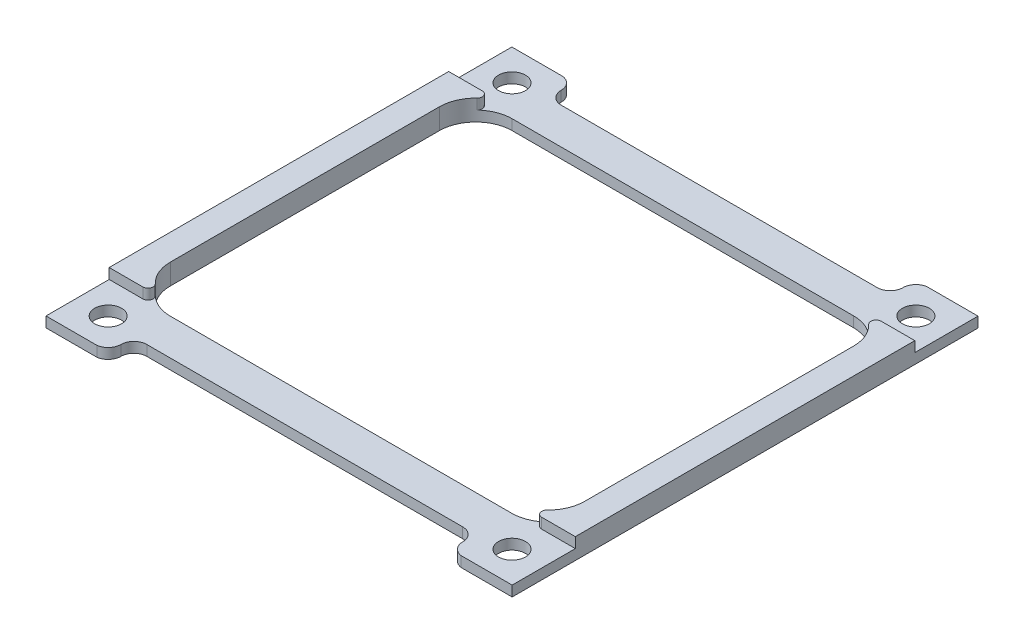
from build123d import *

# Parameters (mm, degrees)
SKETCH_1_W          = 90.03018306390481
SKETCH_1_H          = 89.97022234109225
SKETCH_1_R          = 2.599999999999996
SKETCH_1_W_2        = 65.97077516555349
SKETCH_1_H_2        = 66.02977765890743
EXTRUDE_1_DEPTH     = 2
CUT_EXTRUDE_1_DEPTH = 64.67117630966501
CUT_EXTRUDE_2_DEPTH = 64.67117630966501
EXTRUDE_START       = 2
EXTRUDE_2_DEPTH     = 2
FILLET_1_R          = 1


with BuildPart() as part:
    # 草图1 → 凸台-拉伸1 (new body)
    with BuildSketch(Plane(origin=(0, 0, 0), x_dir=(1, 0, 0), z_dir=(0, 1, 0))):
        Rectangle(SKETCH_1_W, SKETCH_1_H)
        with Locations(Location((39.00000000000001, 38.99999999999999, 0), (0, 0, 270))):
            Circle(SKETCH_1_R, mode=Mode.SUBTRACT)
        with Locations(Location((39.000000000000014, -39.00000000000001, 0), (0, 0, 270))):
            Circle(SKETCH_1_R, mode=Mode.SUBTRACT)
        with Locations(Location((-38.99999999999998, -39.00000000000001, 0), (0, 0, 270))):
            Circle(SKETCH_1_R, mode=Mode.SUBTRACT)
        with Locations(Location((-38.99999999999999, 38.99999999999999, 0), (0, 0, 270))):
            Circle(SKETCH_1_R, mode=Mode.SUBTRACT)
        Rectangle(SKETCH_1_W_2, SKETCH_1_H_2, mode=Mode.SUBTRACT)
    extrude(amount=EXTRUDE_1_DEPTH)

    # 草图3 → 切除-拉伸1 (cut, through all)
    with BuildSketch(Plane(origin=(0, 2, 0), x_dir=(1, 0, 0), z_dir=(0, 1, 0))):
        with BuildLine():
            Line((35.16632906527342, 44.985111170546105), (-35.16632906527342, 44.985111170546126))
            ThreePointArc((-35.16632906527342, 44.98511117054611), (-33.623759393307296, 44.150934913211564), (-33.00868514907322, 42.50866365204603))
            ThreePointArc((-33.00868514907322, 42.50866365204603), (-32.2698933068484, 40.74672362699537), (-30.502504505895168, 40.02106333162392))
            Line((-30.502504505895168, 40.02106333162392), (30.502504505895196, 40.0210633316239))
            ThreePointArc((30.502504505895196, 40.0210633316239), (32.269893306848424, 40.74672362699535), (33.00868514907325, 42.50866365204601))
            ThreePointArc((33.00868514907325, 42.50866365204601), (33.62375939330732, 44.150934913211536), (35.16632906527342, 44.98511117054609))
        make_face()
        with BuildLine():
            Line((30.502504505895207, -40.0210633316239), (-30.502504505895114, -40.02106333162392))
            ThreePointArc((-30.502504505895114, -40.02106333162392), (-32.269893306848346, -40.74672362699537), (-33.008685149073166, -42.50866365204603))
            ThreePointArc((-33.008685149073166, -42.50866365204603), (-33.62375939330724, -44.150934913211564), (-35.166329065273366, -44.98511117054611))
            Line((-35.166329065273366, -44.985111170546126), (35.16632906527344, -44.985111170546105))
            ThreePointArc((35.16632906527343, -44.98511117054609), (33.623759393307324, -44.150934913211536), (33.00868514907326, -42.50866365204601))
            ThreePointArc((33.00868514907326, -42.50866365204601), (32.26989330684843, -40.74672362699535), (30.502504505895203, -40.0210633316239))
        make_face()
    extrude(amount=-CUT_EXTRUDE_1_DEPTH, mode=Mode.SUBTRACT)

    # 草图4 → 切除-拉伸2 (cut, through all)
    with BuildSketch(Plane(origin=(0, 2, 0), x_dir=(1, 0, 0), z_dir=(0, 1, 0))):
        with BuildLine():
            Line((-32.985387582776745, -33.01488882945372), (-32.985387582776724, 33.01488882945372))
            ThreePointArc((-32.985387582776724, 33.01488882945372), (-37.9510386162303, 30.950835913733954), (-40.0150915319524, 25.985184880281345))
            Line((-40.01509153195237, 25.985184880281345), (-40.01509153195237, 25.95025335742635))
            Line((-40.01509153195237, 25.95025335742635), (-40.0150915319524, -25.95025335742637))
            Line((-40.0150915319524, -25.95025335742637), (-40.0150915319524, -25.985184880281345))
            ThreePointArc((-40.015091531952386, -25.985184880281345), (-37.95103861623032, -30.950835913733957), (-32.985387582776745, -33.01488882945372))
        make_face()
        with BuildLine():
            Line((40.01509153195237, 25.950253357426362), (40.01509153195237, 25.985184880281345))
            ThreePointArc((40.0150915319524, 25.985184880281345), (37.9510386162303, 30.95083591373395), (32.985387582776724, 33.01488882945372))
            Line((32.985387582776724, 33.01488882945372), (32.985387582776745, -33.01488882945372))
            ThreePointArc((32.985387582776745, -33.01488882945372), (37.95103861623032, -30.950835913733957), (40.0150915319524, -25.985184880281345))
            Line((40.0150915319524, -25.985184880281345), (40.0150915319524, -25.950253357426362))
            Line((40.0150915319524, -25.950253357426362), (40.01509153195237, 25.950253357426362))
        make_face()
    extrude(amount=-CUT_EXTRUDE_2_DEPTH, mode=Mode.SUBTRACT)

    # 草图5 → 凸台-拉伸2 (add)
    with BuildSketch(Plane(origin=(0, 2, 0), x_dir=(1, 0, 0), z_dir=(0, 1, 0)).offset(EXTRUDE_START)):
        with BuildLine():
            Line((45.015091531952415, -32.78514802541212), (45.015091531952415, 32.78514802541212))
            Line((45.015091531952415, 32.78514802541212), (34.75273808271875, 32.78514802541212))
            ThreePointArc((34.75273808271875, 32.78514802541213), (38.54114967835172, 30.28072702943986), (40.01509153195237, 25.985184880281345))
            Line((40.01509153195237, 25.985184880281345), (40.0150915319524, -25.985184880281345))
            ThreePointArc((40.0150915319524, -25.985184880281345), (38.54114967835175, -30.280727029439863), (34.75273808271877, -32.78514802541212))
            Line((34.75273808271877, -32.78514802541212), (45.015091531952415, -32.78514802541212))
        make_face()
        with BuildLine():
            Line((-45.01509153195241, 32.78514802541209), (-45.01509153195241, -32.78514802541212))
            Line((-45.0150915319524, -32.78514802541212), (-34.75273808271877, -32.78514802541212))
            ThreePointArc((-34.75273808271877, -32.78514802541212), (-38.54114967835175, -30.280727029439863), (-40.0150915319524, -25.985184880281345))
            Line((-40.0150915319524, -25.985184880281345), (-40.01509153195237, 25.985184880281345))
            ThreePointArc((-40.01509153195237, 25.985184880281345), (-38.54114967835173, 30.280727029439863), (-34.75273808271875, 32.78514802541213))
            Line((-34.75273808271875, 32.78514802541212), (-45.01509153195241, 32.78514802541209))
        make_face()
    extrude(amount=-EXTRUDE_2_DEPTH)

    # 圆角1
    fillet_1_edges = [part.edges().sort_by_distance(p)[0] for p in [
        (34.75273808271877, 3, 32.78514802541213),
        (34.75273808271875, 3, -32.78514802541213),
        (-34.75273808271875, 3, -32.78514802541213),
        (-34.75273808271877, 3, 32.78514802541212),
    ]]
    fillet(fillet_1_edges, radius=FILLET_1_R)


solid = part.part
